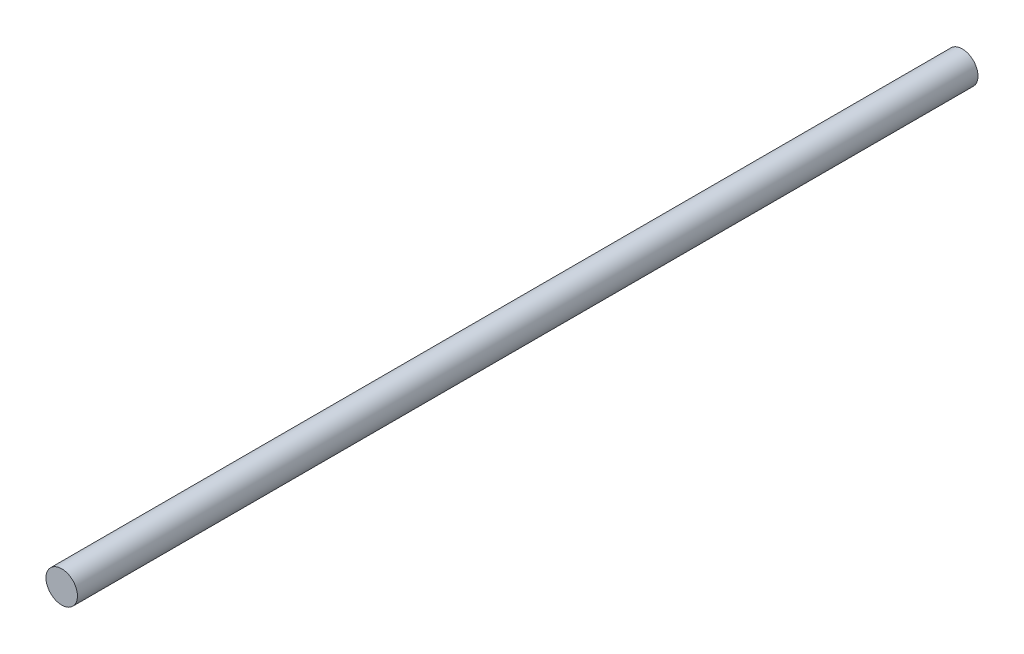
from build123d import *

# Parameters (mm, degrees)
CROQUIS1_R              = 5
SALIENTE_EXTRUIR1_DEPTH = 286


with BuildPart() as part:
    # Croquis1 → Saliente-Extruir1 (new body)
    with BuildSketch(Plane.XY):
        Circle(CROQUIS1_R)
    extrude(amount=SALIENTE_EXTRUIR1_DEPTH)


solid = part.part
